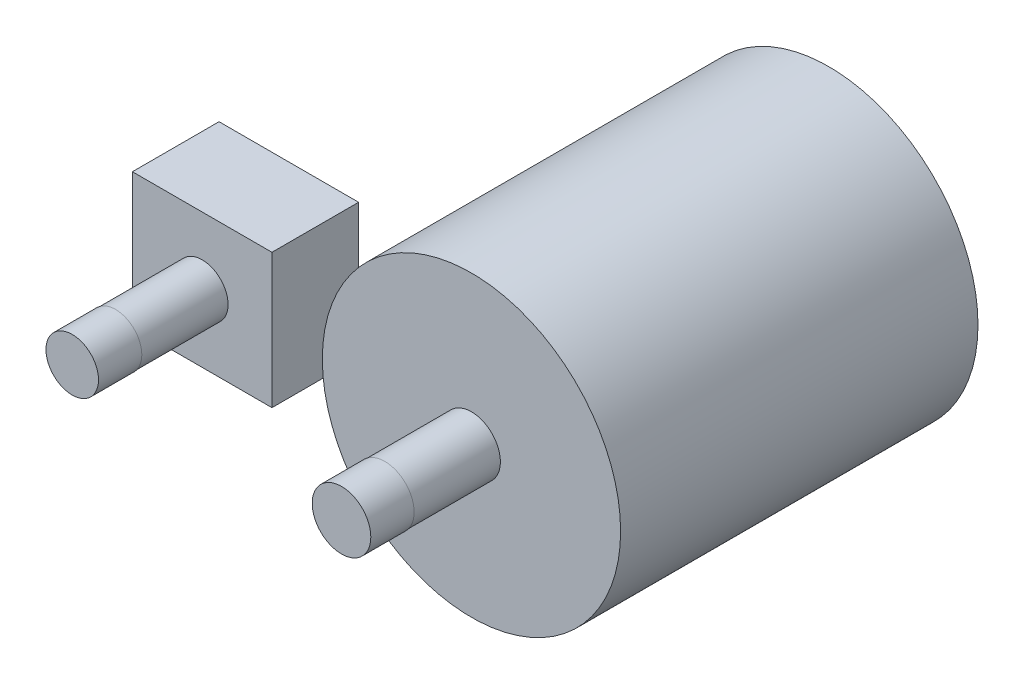
from build123d import *

# Parameters (mm, degrees)
SKETCH2_R           = 13.771311666
BOSS_EXTRUDE1_DEPTH = 33
SKETCH4_R           = 2.670460619
BOSS_EXTRUDE2_DEPTH = 8
SKETCH5_R           = 2.391755936
BOSS_EXTRUDE3_DEPTH = 8
SKETCH6_W           = 12.884717539
SKETCH6_H           = 12.427625198
BOSS_EXTRUDE4_DEPTH = 8
SKETCH23_R          = 2.425954538
BOSS_EXTRUDE6_DEPTH = 4
SKETCH24_R          = 2.7046062
BOSS_EXTRUDE7_DEPTH = 4


with BuildPart() as part:
    # Sketch2 → Boss-Extrude1 (new body)
    with BuildSketch(Plane.XY):
        Circle(SKETCH2_R)
    extrude(amount=BOSS_EXTRUDE1_DEPTH)

    # Sketch4 → Boss-Extrude2 (add)
    with BuildSketch(Plane.XY.offset(33)):
        Circle(SKETCH4_R)
    extrude(amount=BOSS_EXTRUDE2_DEPTH)

    # Sketch24 → Boss-Extrude7 (add)
    with BuildSketch(Plane.XY.offset(41)):
        Circle(SKETCH24_R)
    extrude(amount=BOSS_EXTRUDE7_DEPTH)


with BuildPart() as body_2:
    # Sketch5 → Boss-Extrude3 (new body)
    with BuildSketch(Plane.XY.offset(33)):
        with Locations((-24.864724485, 0)):
            Circle(SKETCH5_R)
    extrude(amount=BOSS_EXTRUDE3_DEPTH)

    # Sketch6 → Boss-Extrude4 (add)
    with BuildSketch(Plane(origin=(0, 0, 33), x_dir=(-1, 0, 0), z_dir=(0, 0, -1))):
        with Locations((24.864724486, 0)):
            Rectangle(SKETCH6_W, SKETCH6_H)
    extrude(amount=BOSS_EXTRUDE4_DEPTH)

    # Sketch23 → Boss-Extrude6 (add)
    with BuildSketch(Plane.XY.offset(41)):
        with Locations((-24.864724485, 0)):
            Circle(SKETCH23_R)
    extrude(amount=BOSS_EXTRUDE6_DEPTH)


solid = Compound([part.part, body_2.part])
